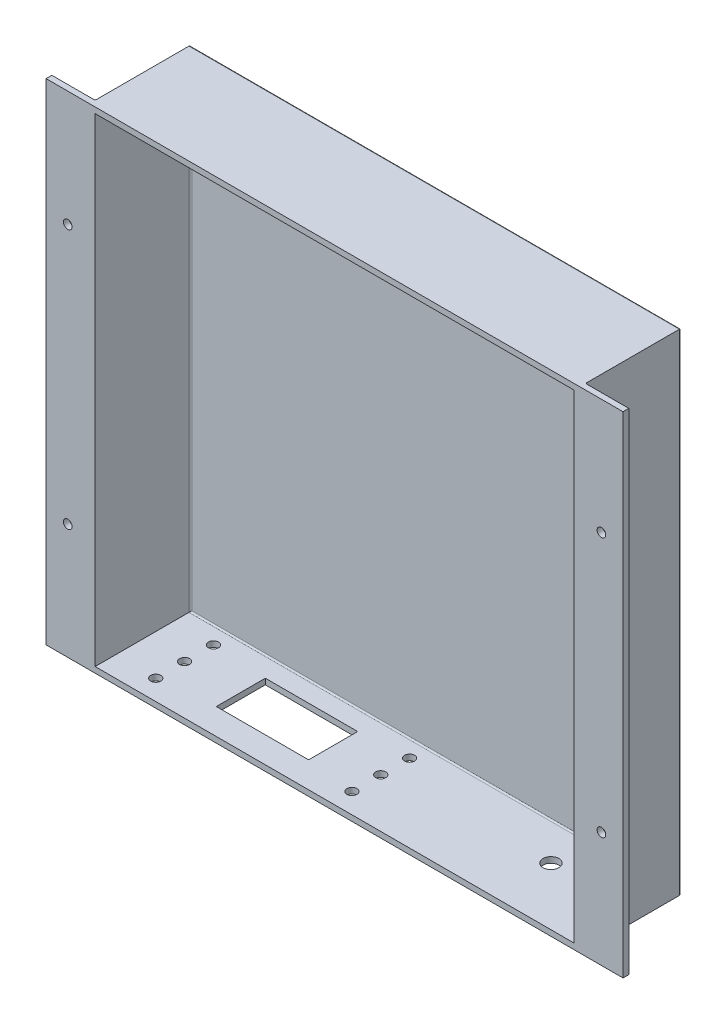
from build123d import *

# Parameters (mm, degrees)
SKETCH1_W                      = 170
SKETCH1_H                      = 170
BOSS_EXTRUDE1_DEPTH            = 35
SKETCH2_W                      = 166
SKETCH2_H                      = 166
CUT_EXTRUDE1_DEPTH             = 33
SKETCH3_W                      = 2
SKETCH3_H                      = 170
BOSS_EXTRUDE2_DEPTH            = 15
SKETCH4_W                      = 2
SKETCH4_H                      = 170
BOSS_EXTRUDE3_DEPTH            = 15
F_3_0_3_DIAMETER_HOLE1_D       = 3
F_3_0_3_DIAMETER_HOLE1_DEPTH   = 100
F_3_0_3_DIAMETER_HOLE1_TIP     = 0.901290929
SKETCH7_R                      = 2.75
SKETCH7_W                      = 32
SKETCH7_H                      = 17
CUT_EXTRUDE2_DEPTH             = 15
FILLET1_R                      = 0.5
F_3_5_3_5_DIAMETER_HOLE1_D     = 3.5
F_3_5_3_5_DIAMETER_HOLE1_DEPTH = 100
F_3_5_3_5_DIAMETER_HOLE1_TIP   = 1.051506083


with BuildPart() as part:
    # Sketch1 → Boss-Extrude1 (new body)
    with BuildSketch(Plane.XY):
        Rectangle(SKETCH1_W, SKETCH1_H)
    extrude(amount=BOSS_EXTRUDE1_DEPTH)

    # Sketch2 → Cut-Extrude1 (cut)
    with BuildSketch(Plane.XY.offset(35)):
        Rectangle(SKETCH2_W, SKETCH2_H)
    extrude(amount=-CUT_EXTRUDE1_DEPTH, mode=Mode.SUBTRACT)

    # Sketch3 → Boss-Extrude2 (add)
    with BuildSketch(Plane(origin=(85, 0, 0), x_dir=(0, 0, -1), z_dir=(1, 0, 0))):
        with Locations((-34, 0)):
            Rectangle(SKETCH3_W, SKETCH3_H)
    extrude(amount=BOSS_EXTRUDE2_DEPTH)

    # Sketch4 → Boss-Extrude3 (add)
    with BuildSketch(Plane.ZY.offset(85)):
        with Locations((34, 0)):
            Rectangle(SKETCH4_W, SKETCH4_H)
    extrude(amount=BOSS_EXTRUDE3_DEPTH)

    # Ø3.0 (3) Diameter Hole1
    with Locations(Plane.XY.offset(35)):
        with Locations((-92.5, 45), (-92.5, -45), (115, -45), (115, 45), (92.5, 45), (92.5, -45)):
            Hole(F_3_0_3_DIAMETER_HOLE1_D / 2, depth=F_3_0_3_DIAMETER_HOLE1_DEPTH)
            with Locations((0, 0, -(F_3_0_3_DIAMETER_HOLE1_DEPTH + F_3_0_3_DIAMETER_HOLE1_TIP / 2))):  # 118° drill point
                Cone(0, F_3_0_3_DIAMETER_HOLE1_D / 2, F_3_0_3_DIAMETER_HOLE1_TIP, mode=Mode.SUBTRACT)

    # Sketch7 → Cut-Extrude2 (cut)
    with BuildSketch(Plane.XZ.offset(85)):
        with Locations((55, 15)):
            Circle(SKETCH7_R)
        with Locations((70, 15)):
            Circle(SKETCH7_R)
        with Locations((-34, 17.5)):
            Rectangle(SKETCH7_W, SKETCH7_H)
    extrude(amount=-CUT_EXTRUDE2_DEPTH, mode=Mode.SUBTRACT)

    # Fillet1
    fillet1_edges = [part.edges().sort_by_distance(p)[0] for p in [
        (-83, 0, 2),
        (83, 0, 2),
        (85, 0, 0),
        (85, 0, 33),
        (-85, 0, 0),
        (-85, 0, 33),
        (0, -85, 0),
        (0, 85, 0),
        (0, -83, 2),
    ]]
    fillet(fillet1_edges, radius=FILLET1_R)

    # Ø3.5 (3.5) Diameter Hole1
    with Locations(Plane.XZ.offset(85)):
        with Locations((-69, 28), (-1, 28), (-69, 18), (-1, 18), (-69, 8), (-1, 8)):
            Hole(F_3_5_3_5_DIAMETER_HOLE1_D / 2, depth=F_3_5_3_5_DIAMETER_HOLE1_DEPTH)
            with Locations((0, 0, -(F_3_5_3_5_DIAMETER_HOLE1_DEPTH + F_3_5_3_5_DIAMETER_HOLE1_TIP / 2))):  # 118° drill point
                Cone(0, F_3_5_3_5_DIAMETER_HOLE1_D / 2, F_3_5_3_5_DIAMETER_HOLE1_TIP, mode=Mode.SUBTRACT)


solid = part.part
